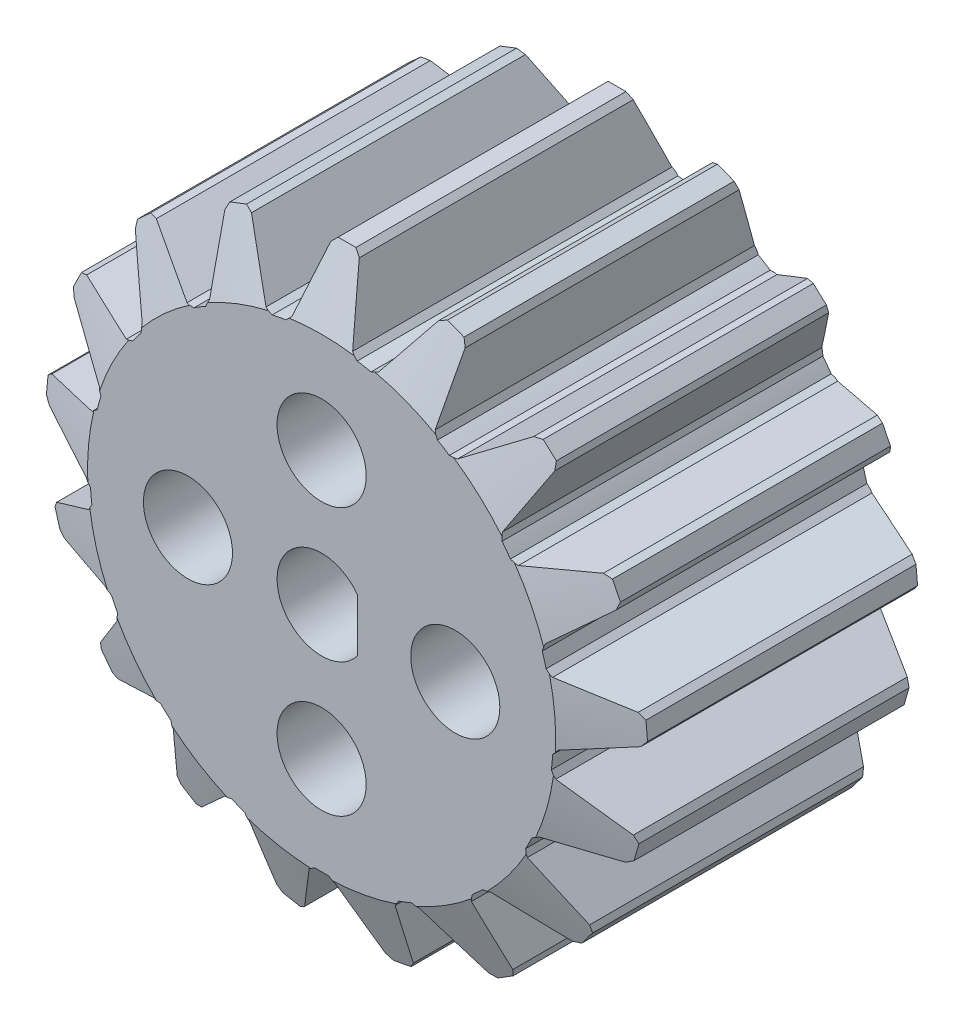
from build123d import *

# Parameters (mm, degrees)
SKETCH1_R           = 12.99
BOSS_EXTRUDE1_DEPTH = 18
CIRPATTERN1_COUNT   = 17
CUT_EXTRUDE1_DEPTH  = 37
SKETCH6_R           = 2.5
CUT_EXTRUDE2_DEPTH  = 37


with BuildPart() as part:
    # Sketch1 → Boss-Extrude1 (new body)
    with BuildSketch(Plane.XY):
        Circle(SKETCH1_R)
    extrude(amount=BOSS_EXTRUDE1_DEPTH)

    # Sweep1: sweep along a curve in space
    with BuildLine() as sweep1_path:
        Line((0, 16.893962479, 18), (0, 16.893962479, -2.071823773))
    # Sketch2 → Sweep1 (sweep)
    with BuildSketch(Plane.XY.offset(18)):
        with BuildLine():
            Line((-0.8, 16.592601931), (-1.7, 13.135111998))
            Line((-1.7, 13.135111998), (-2, 12.835111998))
            Line((-2, 12.835111998), (-2, 12.117296455))
            Line((-2, 12.117296455), (2, 12.117296455))
            Line((2, 12.117296455), (2, 12.835111998))
            Line((2, 12.835111998), (1.7, 13.135111998))
            Line((1.7, 13.135111998), (0.8, 16.592601931))
            Line((0.8, 16.592601931), (0.5, 16.892601931))
            ThreePointArc((0.5, 16.892601931), (0, 16.893962479), (-0.5, 16.892601931))
            Line((-0.5, 16.892601931), (-0.8, 16.592601931))
        make_face()
    sweep1 = sweep(path=sweep1_path.line)

    # CirPattern1: Sweep1 ×17 about axis
    cirpattern1_axis = Axis((0, 0, 0), (0, 0, 1))
    for i in range(1, CIRPATTERN1_COUNT):
        add(sweep1.rotate(cirpattern1_axis, i * 360 / CIRPATTERN1_COUNT))

    # Sketch4 → Cut-Extrude1 (cut)
    with BuildSketch(Plane.XY.offset(18)):
        with BuildLine():
            Line((2, 1.5), (2, -1.5))
            ThreePointArc((2, -1.5), (-2.5, 0), (2, 1.5))
        make_face()
    extrude(amount=-CUT_EXTRUDE1_DEPTH, mode=Mode.SUBTRACT)

    # Sketch5 → Cut-Revolve1 (revolve, cut)
    with BuildSketch(Plane(origin=(0, 0, 0), x_dir=(0, 0, -1), z_dir=(1, 0, 0))):
        Polygon((-22.180054692, 9.637289998), (-22.180054692, 25.200211097), (5.974041984, 25.200211097), (5.974041984, 9.637289998), (0, 9.637289998), (0, 13.135111998), (-1.427061735, 16.909899722), (-16.572938265, 16.909899722), (-18, 13.135111998), (-18, 9.637289998), align=None)
    revolve(axis=Axis((0, 0, 0), (0, 0, 1)), mode=Mode.SUBTRACT)

    # Sketch6 → Cut-Extrude2 (cut)
    with BuildSketch(Plane.XY.offset(18)):
        with Locations((0, 7.5)):
            Circle(SKETCH6_R)
        with Locations((7.5, 0)):
            Circle(SKETCH6_R)
        with Locations((0, -7.5)):
            Circle(SKETCH6_R)
        with Locations((-7.5, 0)):
            Circle(SKETCH6_R)
    extrude(amount=-CUT_EXTRUDE2_DEPTH, mode=Mode.SUBTRACT)


solid = part.part
